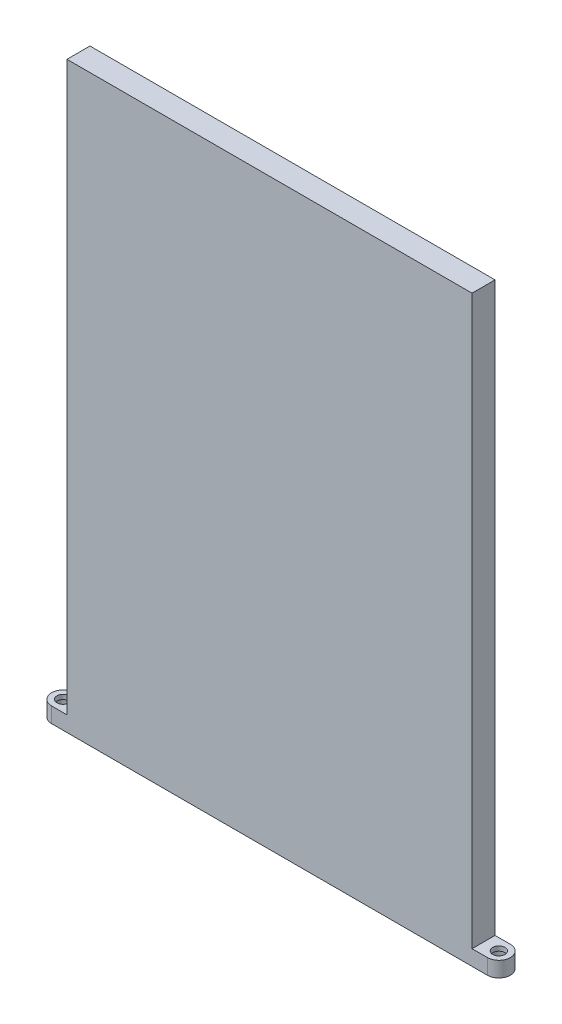
from build123d import *

# Parameters (mm, degrees)
SKETCH1_W           = 132
SKETCH1_H           = 190
BOSS_EXTRUDE1_DEPTH = 7.5
SKETCH2_W           = 5
SKETCH2_H           = 7.5
BOSS_EXTRUDE2_DEPTH = 5
SKETCH3_R           = 2
CUT_EXTRUDE1_DEPTH  = 5
SKETCH4_R           = 3
CUT_EXTRUDE2_DEPTH  = 3.5


with BuildPart() as part:
    # Sketch1 → Boss-Extrude1 (new body)
    with BuildSketch(Plane.XY):
        Rectangle(SKETCH1_W, SKETCH1_H)
    extrude(amount=BOSS_EXTRUDE1_DEPTH)

    # Sketch2 → Boss-Extrude2 (add)
    with BuildSketch(Plane(origin=(0, -95, 0), x_dir=(-1, 0, 0), z_dir=(0, -1, 0))):
        with BuildLine():
            ThreePointArc((71, 0), (74.75, -3.75), (71, -7.5))
            Line((71, -7.5), (71, 0))
        make_face()
        with Locations((68.5, -3.75)):
            Rectangle(SKETCH2_W, SKETCH2_H)
        with BuildLine():
            ThreePointArc((-71, -7.5), (-74.75, -3.75), (-71, 0))
            Line((-71, 0), (-71, -7.5))
        make_face()
        with Locations((-68.5, -3.75)):
            Rectangle(SKETCH2_W, SKETCH2_H)
    extrude(amount=-BOSS_EXTRUDE2_DEPTH)

    # Sketch3 → Cut-Extrude1 (cut)
    with BuildSketch(Plane(origin=(0, -95, 0), x_dir=(-1, 0, 0), z_dir=(0, -1, 0))):
        with Locations((71, -3.75)):
            Circle(SKETCH3_R)
        with Locations((-71, -3.75)):
            Circle(SKETCH3_R)
    extrude(amount=-CUT_EXTRUDE1_DEPTH, mode=Mode.SUBTRACT)

    # Sketch4 → Cut-Extrude2 (cut)
    with BuildSketch(Plane(origin=(0, -95, 0), x_dir=(-1, 0, 0), z_dir=(0, -1, 0))):
        with Locations((71, -3.75)):
            Circle(SKETCH4_R)
        with Locations((-71, -3.75)):
            Circle(SKETCH4_R)
    extrude(amount=-CUT_EXTRUDE2_DEPTH, mode=Mode.SUBTRACT)


solid = part.part
